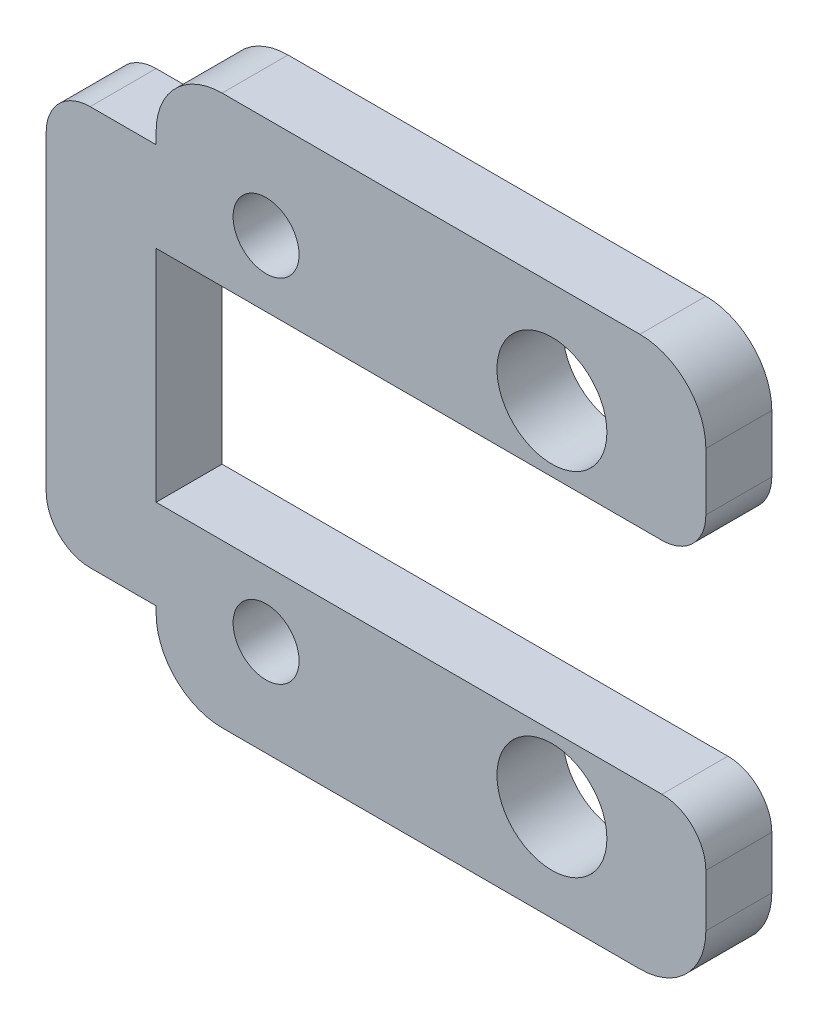
from build123d import *

# Parameters (mm, degrees)
SKETCH1_R           = 2.5
SKETCH1_R_2         = 1.5
BOSS_EXTRUDE1_DEPTH = 3


with BuildPart() as part:
    # Sketch1 → Boss-Extrude1 (new body)
    with BuildSketch(Plane.XY):
        with BuildLine():
            Line((-47.882351022, -2.615594916), (-50.382351022, -2.615594916))
            Line((-50.382351022, -2.615594916), (-55.382351022, -2.615594916))
            Line((-55.382351022, -2.615594916), (-70.882351022, -2.615594916))
            Line((-70.882351022, -2.615594916), (-70.882351022, 7.384405084))
            Line((-70.882351022, 7.384405084), (-55.382351022, 7.384405084))
            Line((-55.382351022, 7.384405084), (-50.382351022, 7.384405084))
            Line((-50.382351022, 7.384405084), (-47.882351022, 7.384405084))
            ThreePointArc((-47.882351022, 7.384405084), (-46.46813746, 7.970191522), (-45.882351022, 9.384405084))
            Line((-45.882351022, 9.384405084), (-45.882351022, 12))
            ThreePointArc((-45.882351022, 12), (-46.761030678, 14.121320344), (-48.882351022, 15))
            Line((-48.882351022, 15), (-67.882351022, 15))
            ThreePointArc((-67.882351022, 15), (-70.003671365, 14.121320344), (-70.882351022, 12))
            Line((-70.882351022, 12), (-70.882351022, 11.465621828))
            Line((-70.882351022, 11.465621828), (-73.882351022, 11.465621828))
            ThreePointArc((-73.882351022, 11.465621828), (-75.296564584, 10.879835391), (-75.882351022, 9.465621828))
            Line((-75.882351022, 9.465621828), (-75.882351022, -4.69681166))
            ThreePointArc((-75.882351022, -4.69681166), (-75.296564584, -6.111025222), (-73.882351022, -6.69681166))
            Line((-73.882351022, -6.69681166), (-70.882351022, -6.69681166))
            Line((-70.882351022, -6.69681166), (-70.882351022, -7))
            ThreePointArc((-70.882351022, -7), (-70.003671365, -9.121320344), (-67.882351022, -10))
            Line((-67.882351022, -10), (-48.882351022, -10))
            ThreePointArc((-48.882351022, -10), (-46.761030678, -9.121320344), (-45.882351022, -7))
            Line((-45.882351022, -7), (-45.882351022, -4.615594916))
            ThreePointArc((-45.882351022, -4.615594916), (-46.46813746, -3.201381353), (-47.882351022, -2.615594916))
        make_face()
        with Locations((-52.882351022, 10.384405084)):
            Circle(SKETCH1_R, mode=Mode.SUBTRACT)
        with Locations((-52.882351022, -5.615594916)):
            Circle(SKETCH1_R, mode=Mode.SUBTRACT)
        with Locations((-65.882351022, 10.384405084)):
            Circle(SKETCH1_R_2, mode=Mode.SUBTRACT)
        with Locations((-65.882351022, -5.615594916)):
            Circle(SKETCH1_R_2, mode=Mode.SUBTRACT)
    extrude(amount=BOSS_EXTRUDE1_DEPTH)


solid = part.part
